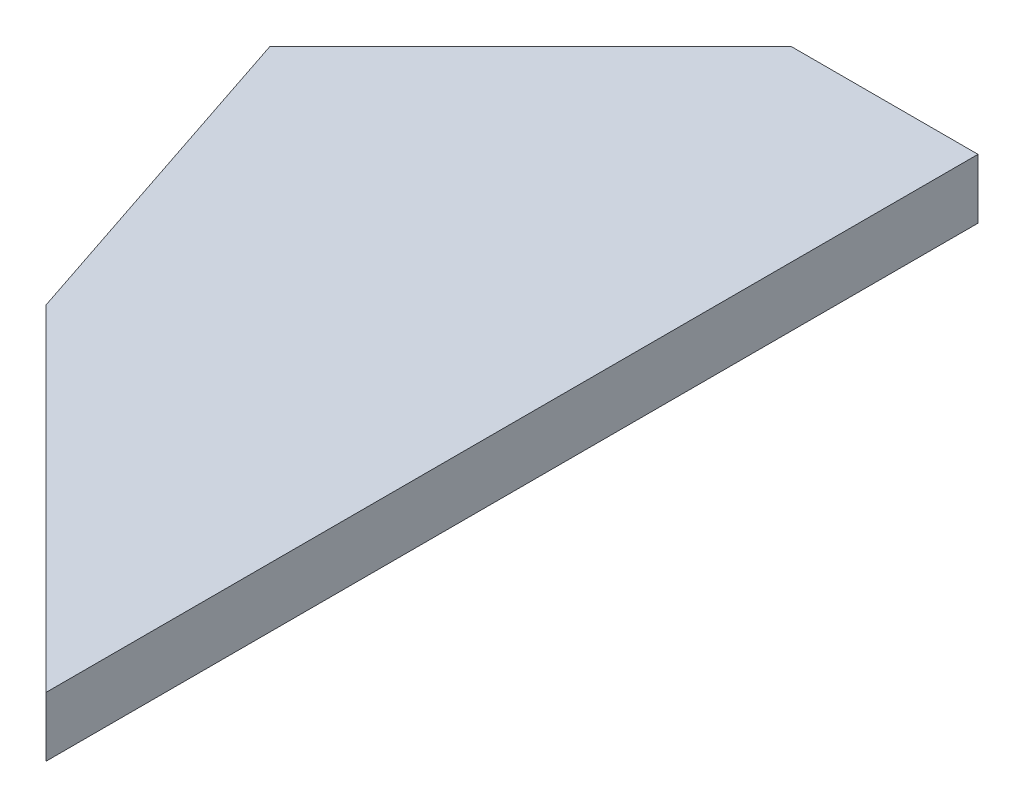
from build123d import *

# Parameters (mm, degrees)
EXTRUDE_C_DEPTH = 6.4


with BuildPart() as part:
    # puzzle plan_5 → Extrude C (new body)
    with BuildSketch(Plane(origin=(0, 0, 0), x_dir=(1, 0, 0), z_dir=(0, 1, 0))):
        Polygon((80, 100), (52, 72), (64, 36), (100, 0), (100, 100), align=None)
    extrude(amount=EXTRUDE_C_DEPTH)


solid = part.part
